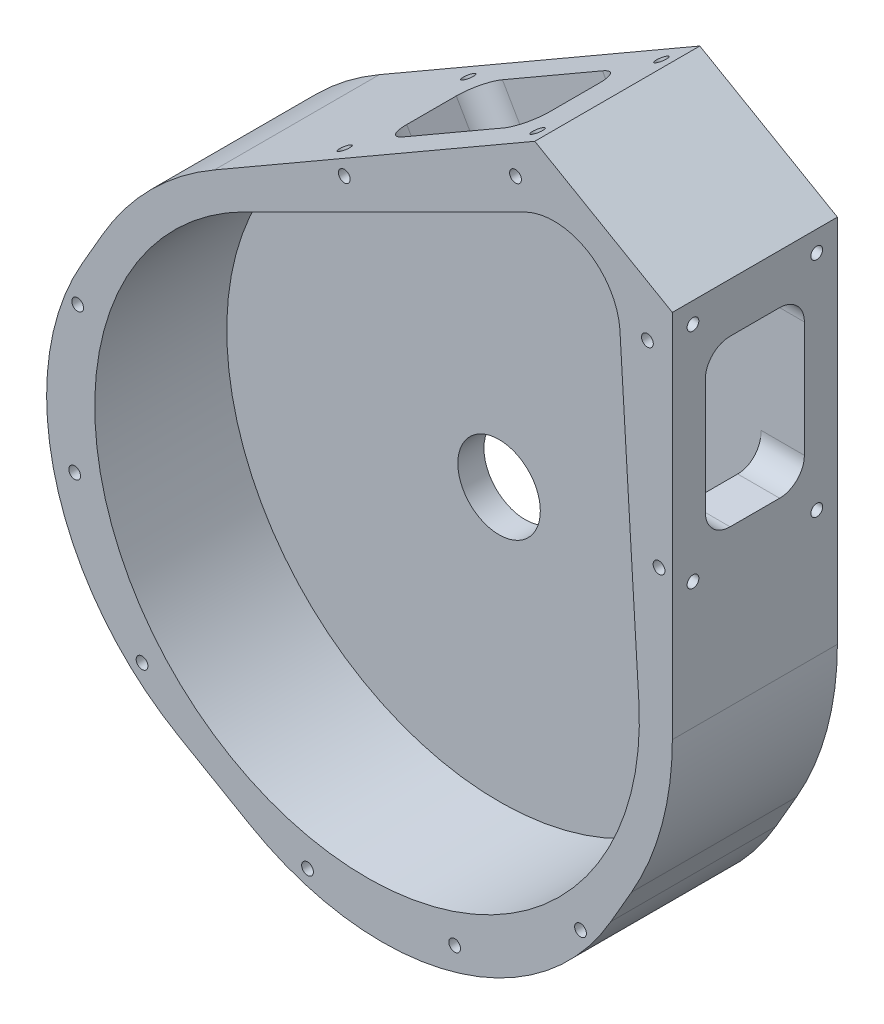
from build123d import *

# Parameters (mm, degrees)
BOSS_EXTRUDE1_DEPTH            = 31.75
CUT_EXTRUDE3_DEPTH             = 25.4
CUT_EXTRUDE4_DEPTH             = 41.472686
F_4_40_TAPPED_HOLE1_AT_2_COUNT = 2
F_4_40_TAPPED_HOLE1_AT_2_PITCH = 23.8125
F_4_40_TAPPED_HOLE1_AT_3_COUNT = 2
F_4_40_TAPPED_HOLE1_AT_3_PITCH = 49.032938546
F_4_40_TAPPED_HOLE1_AT_4_COUNT = 2
F_4_40_TAPPED_HOLE1_AT_4_PITCH = 42.8625
F_4_40_TAPPED_HOLE3_AT_2_COUNT = 2
F_4_40_TAPPED_HOLE3_AT_2_PITCH = 105.48665894
F_4_40_TAPPED_HOLE3_AT_3_COUNT = 2
F_4_40_TAPPED_HOLE3_AT_3_PITCH = 124.969097047
F_4_40_TAPPED_HOLE3_AT_4_COUNT = 2
F_4_40_TAPPED_HOLE3_AT_4_PITCH = 36.810720416
F_4_40_TAPPED_HOLE3_AT_5_COUNT = 2
F_4_40_TAPPED_HOLE3_AT_5_PITCH = 137.285419975
SKETCH23_R                     = 7.9375
CUT_EXTRUDE6_DEPTH             = 32.75
SKETCH24_R                     = 10.0076
CUT_EXTRUDE9_DEPTH             = 1.3208
F_2_56_TAPPED_HOLE1_AT_2_COUNT = 2
F_2_56_TAPPED_HOLE1_AT_2_PITCH = 23.23749988
F_2_56_TAPPED_HOLE1_AT_3_COUNT = 2
F_2_56_TAPPED_HOLE1_AT_3_PITCH = 32.862787571
F_2_56_TAPPED_HOLE1_AT_4_COUNT = 2
F_2_56_TAPPED_HOLE1_AT_4_PITCH = 23.2375
LPATTERN1_COUNT                = 2
LPATTERN1_PITCH                = 71.501
F_4_40_TAPPED_HOLE5_AT_2_COUNT = 2
F_4_40_TAPPED_HOLE5_AT_2_PITCH = 12.7
F_4_40_TAPPED_HOLE5_AT_3_COUNT = 2
F_4_40_TAPPED_HOLE5_AT_3_PITCH = 95.193833559
FILLET3_R                      = 50.8


with BuildPart() as part:
    # Sketch1 (on Front Plane) → Boss-Extrude1 (new body)
    with BuildSketch(Plane.XY):
        with BuildLine():
            Line((58.7375, 0), (58.7375, 71.178534783))
            Line((58.7375, 71.178534783), (32.273669326, 86.457434546))
            Line((32.273669326, 86.457434546), (-29.36875, 50.868167155))
            ThreePointArc((-29.36875, 50.868167155), (-41.53368456, 41.53368456), (-50.868167155, 29.36875))
            Line((-50.868167155, 29.36875), (-80.236917155, -21.499417155))
            Line((-80.236917155, -21.499417155), (21.499417155, -80.236917155))
            Line((21.499417155, -80.236917155), (50.868167155, -29.36875))
            ThreePointArc((50.868167155, -29.36875), (56.736068222, -15.202383662), (58.7375, 0))
        make_face()
    extrude(amount=BOSS_EXTRUDE1_DEPTH)

    # Sketch4 → Cut-Extrude3 (cut)
    with BuildSketch(Plane.XY.offset(31.75)):
        with BuildLine():
            Line((30.568366553, 73.812917761), (-23.525977534, 46.807889691))
            ThreePointArc((-23.525977534, 46.807889691), (-26.19375, -45.368905841), (52.299810337, 3.029850652))
            Line((52.299810337, 3.029850652), (48.639678632, 63.379440867))
            ThreePointArc((48.639678632, 63.379440867), (42.332250779, 73.321609148), (30.568366553, 73.812917761))
        make_face()
    extrude(amount=-CUT_EXTRUDE3_DEPTH, mode=Mode.SUBTRACT)

    # Sketch5 → Cut-Extrude4 (cut)
    with BuildSketch(Plane(origin=(58.7375, 0, 0), x_dir=(0, 0, -1), z_dir=(1, 0, 0))):
        with BuildLine():
            Line((-20.6375, 29.903534783), (-11.1125, 29.903534783))
            ThreePointArc((-11.1125, 29.903534783), (-7.744903955, 31.298438737), (-6.35, 34.666034783))
            Line((-6.35, 34.666034783), (-6.35, 56.891034783))
            ThreePointArc((-6.35, 56.891034783), (-7.744903955, 60.258630828), (-11.1125, 61.653534783))
            Line((-11.1125, 61.653534783), (-20.6375, 61.653534783))
            ThreePointArc((-20.6375, 61.653534783), (-24.005096045, 60.258630828), (-25.4, 56.891034783))
            Line((-25.4, 56.891034783), (-25.4, 34.666034783))
            ThreePointArc((-25.4, 34.666034783), (-24.005096045, 31.298438737), (-20.6375, 29.903534783))
        make_face()
    cut_extrude4 = extrude(amount=-CUT_EXTRUDE4_DEPTH, mode=Mode.SUBTRACT)

    # Sketch11 → #4-40 Tapped Hole1 (revolve, cut)
    with BuildSketch(Plane(origin=(58.7375, 24.347284783, 27.78125), x_dir=(0, 0, -1), z_dir=(0, 1, 0))):
        Polygon((0, 0), (0, 5.759152758), (1.1303, 5.08), (1.1303, 0), align=None)
    f_4_40_tapped_hole1 = revolve(axis=Axis((65.0875, 24.347284783, 27.78125), (-1, 0, 0)), mode=Mode.SUBTRACT)

    # #4-40 Tapped Hole1 at 2: #4-40 Tapped Hole1 ×2
    with Locations(*[(0, 0, -i * F_4_40_TAPPED_HOLE1_AT_2_PITCH) for i in range(1, F_4_40_TAPPED_HOLE1_AT_2_COUNT)]):
        add(f_4_40_tapped_hole1, mode=Mode.SUBTRACT)

    # #4-40 Tapped Hole1 at 3: #4-40 Tapped Hole1 ×2
    with Locations(*[Vector(0, 0.874157276, -0.485642931) * (i * F_4_40_TAPPED_HOLE1_AT_3_PITCH) for i in range(1, F_4_40_TAPPED_HOLE1_AT_3_COUNT)]):
        add(f_4_40_tapped_hole1, mode=Mode.SUBTRACT)

    # #4-40 Tapped Hole1 at 4: #4-40 Tapped Hole1 ×2
    with Locations(*[(0, i * F_4_40_TAPPED_HOLE1_AT_4_PITCH, 0) for i in range(1, F_4_40_TAPPED_HOLE1_AT_4_COUNT)]):
        add(f_4_40_tapped_hole1, mode=Mode.SUBTRACT)

    # Mirror1: #4-40 Tapped Hole1, Cut-Extrude4 across plane
    add(f_4_40_tapped_hole1.mirror(Plane(origin=(45.505584663, 78.817984664, 31.75), x_dir=(0, 0, 1), z_dir=(-0.866025404, 0.5, 0))), mode=Mode.SUBTRACT)
    add(cut_extrude4.mirror(Plane(origin=(45.505584663, 78.817984664, 31.75), x_dir=(0, 0, 1), z_dir=(-0.866025404, 0.5, 0))), mode=Mode.SUBTRACT)

    # Mirror1 copy 1 sketch → Mirror1 copy 1 (revolve, cut)
    with BuildSketch(Plane(origin=(-8.283382865, 63.041809546, 3.96875), x_dir=(0, 0, -1), z_dir=(0.866025404, 0.5, 0))):
        Polygon((0, 0), (0, -5.759152758), (1.1303, -5.08), (1.1303, 0), align=None)
    revolve(axis=Axis((-11.458382865, 68.54107086, 3.96875), (-0.5, 0.866025404, 0)), mode=Mode.SUBTRACT)

    # Mirror1 copy 2 sketch → Mirror1 copy 2 (revolve, cut)
    with BuildSketch(Plane(origin=(28.836631005, 84.473059546, 3.96875), x_dir=(0, 0, -1), z_dir=(0.866025404, 0.5, 0))):
        Polygon((0, 0), (0, -5.759152758), (1.1303, -5.08), (1.1303, 0), align=None)
    revolve(axis=Axis((25.661631005, 89.97232086, 3.96875), (-0.5, 0.866025404, 0)), mode=Mode.SUBTRACT)

    # Mirror1 copy 3 sketch → Mirror1 copy 3 (revolve, cut)
    with BuildSketch(Plane(origin=(28.836631005, 84.473059546, 27.78125), x_dir=(0, 0, -1), z_dir=(0.866025404, 0.5, 0))):
        Polygon((0, 0), (0, -5.759152758), (1.1303, -5.08), (1.1303, 0), align=None)
    revolve(axis=Axis((25.661631005, 89.97232086, 27.78125), (-0.5, 0.866025404, 0)), mode=Mode.SUBTRACT)

    # Sketch21 → #4-40 Tapped Hole3 (revolve, cut)
    with BuildSketch(Plane(origin=(28.563997799, 78.776138947, 31.75), x_dir=(0, -1, 0), z_dir=(1, 0, 0))):
        Polygon((0, 0), (0, 9.569152758), (1.1303, 8.89), (1.1303, 0), align=None)
    f_4_40_tapped_hole3 = revolve(axis=Axis((28.563997799, 78.776138947, 38.1), (0, 0, -1)), mode=Mode.SUBTRACT)

    # #4-40 Tapped Hole3 at 2: #4-40 Tapped Hole3 ×2
    with Locations(*[Vector(-0.798570247, -0.60190162, 0) * (i * F_4_40_TAPPED_HOLE3_AT_2_PITCH) for i in range(1, F_4_40_TAPPED_HOLE3_AT_2_COUNT)]):
        add(f_4_40_tapped_hole3, mode=Mode.SUBTRACT)

    # #4-40 Tapped Hole3 at 3: #4-40 Tapped Hole3 ×2
    with Locations(*[Vector(-0.678682797, -0.734431522, 0) * (i * F_4_40_TAPPED_HOLE3_AT_3_PITCH) for i in range(1, F_4_40_TAPPED_HOLE3_AT_3_COUNT)]):
        add(f_4_40_tapped_hole3, mode=Mode.SUBTRACT)

    # #4-40 Tapped Hole3 at 4: #4-40 Tapped Hole3 ×2
    with Locations(*[Vector(-0.894837014, -0.44639301, 0) * (i * F_4_40_TAPPED_HOLE3_AT_4_PITCH) for i in range(1, F_4_40_TAPPED_HOLE3_AT_4_COUNT)]):
        add(f_4_40_tapped_hole3, mode=Mode.SUBTRACT)

    # #4-40 Tapped Hole3 at 5: #4-40 Tapped Hole3 ×2
    with Locations(*[Vector(-0.523334145, -0.852127557, 0) * (i * F_4_40_TAPPED_HOLE3_AT_5_PITCH) for i in range(1, F_4_40_TAPPED_HOLE3_AT_5_COUNT)]):
        add(f_4_40_tapped_hole3, mode=Mode.SUBTRACT)

    # Mirror2: #4-40 Tapped Hole3 across plane
    add(f_4_40_tapped_hole3.mirror(Plane(origin=(45.505584663, 78.817984664, 31.75), x_dir=(0, 0, 1), z_dir=(-0.866025404, 0.5, 0))), mode=Mode.SUBTRACT)

    # Mirror2 copy 1 sketch → Mirror2 copy 1 (revolve, cut)
    with BuildSketch(Plane(origin=(41.073195613, -40.573765561, 31.75), x_dir=(-0.866025404, -0.5, 0), z_dir=(-0.5, 0.866025404, 0))):
        Polygon((0, 0), (0, -9.569152758), (1.1303, -8.89), (1.1303, 0), align=None)
    revolve(axis=Axis((41.073195613, -40.573765561, 38.1), (0, 0, 1)), mode=Mode.SUBTRACT)

    # Mirror2 copy 2 sketch → Mirror2 copy 2 (revolve, cut)
    with BuildSketch(Plane(origin=(16.862437785, -55.216809411, 31.75), x_dir=(-0.866025404, -0.5, 0), z_dir=(-0.5, 0.866025404, 0))):
        Polygon((0, 0), (0, -9.569152758), (1.1303, -8.89), (1.1303, 0), align=None)
    revolve(axis=Axis((16.862437785, -55.216809411, 38.1), (0, 0, 1)), mode=Mode.SUBTRACT)

    # Mirror2 copy 3 sketch → Mirror2 copy 3 (revolve, cut)
    with BuildSketch(Plane(origin=(56.179364962, 27.382666896, 31.75), x_dir=(-0.866025404, -0.5, 0), z_dir=(-0.5, 0.866025404, 0))):
        Polygon((0, 0), (0, -9.569152758), (1.1303, -8.89), (1.1303, 0), align=None)
    revolve(axis=Axis((56.179364962, 27.382666896, 38.1), (0, 0, 1)), mode=Mode.SUBTRACT)

    # Mirror2 copy 4 sketch → Mirror2 copy 4 (revolve, cut)
    with BuildSketch(Plane(origin=(-11.448500353, -56.58771677, 31.75), x_dir=(-0.866025404, -0.5, 0), z_dir=(-0.5, 0.866025404, 0))):
        Polygon((0, 0), (0, -9.569152758), (1.1303, -8.89), (1.1303, 0), align=None)
    revolve(axis=Axis((-11.448500353, -56.58771677, 38.1), (0, 0, 1)), mode=Mode.SUBTRACT)

    # Sketch23 → Cut-Extrude6 (cut, through all)
    with BuildSketch(Plane(origin=(0, 0, 0), x_dir=(-1, 0, 0), z_dir=(0, 0, -1))):
        Circle(SKETCH23_R)
        with Locations((-35.818522025, 62.0395)):
            Circle(SKETCH23_R)
    extrude(amount=-CUT_EXTRUDE6_DEPTH, mode=Mode.SUBTRACT)

    # Sketch24 → Cut-Extrude9 (cut)
    with BuildSketch(Plane(origin=(0, 0, 0), x_dir=(-1, 0, 0), z_dir=(0, 0, -1))):
        Circle(SKETCH24_R)
        with Locations((-35.818522025, 62.0395)):
            Circle(SKETCH24_R)
    extrude(amount=-CUT_EXTRUDE9_DEPTH, mode=Mode.SUBTRACT)

    # Sketch26 → #4-40 Tapped Hole4 (revolve, cut)
    with BuildSketch(Plane(origin=(35.818522025, 46.0375, 6.35), x_dir=(0, -1, 0), z_dir=(1, 0, 0))):
        Polygon((0, 0), (0, 4.997152758), (1.1303, 4.318), (1.1303, 0), align=None)
    f_4_40_tapped_hole4 = revolve(axis=Axis((35.818522025, 46.0375, 12.7), (0, 0, -1)), mode=Mode.SUBTRACT)

    # Mirror3: #4-40 Tapped Hole4 across plane
    add(f_4_40_tapped_hole4.mirror(Plane(origin=(45.505584663, 78.817984664, 31.75), x_dir=(0, 0, 1), z_dir=(-0.866025404, 0.5, 0))), mode=Mode.SUBTRACT)

    # Sketch28 → #2-56 Tapped Hole1 (revolve, cut)
    with BuildSketch(Plane(origin=(51.690029634, 66.29225769, 0), x_dir=(0, 1, 0), z_dir=(1, 0, 0))):
        Polygon((0, 0), (0, 4.34416509), (0.889, 3.81), (0.889, 0), align=None)
    f_2_56_tapped_hole1 = revolve(axis=Axis((51.690029634, 66.29225769, -6.35), (0, 0, 1)), mode=Mode.SUBTRACT)

    # #2-56 Tapped Hole1 at 2: #2-56 Tapped Hole1 ×2
    with Locations(*[Vector(-0.866025404, 0.5, 0) * (i * F_2_56_TAPPED_HOLE1_AT_2_PITCH) for i in range(1, F_2_56_TAPPED_HOLE1_AT_2_COUNT)]):
        add(f_2_56_tapped_hole1, mode=Mode.SUBTRACT)

    # #2-56 Tapped Hole1 at 3: #2-56 Tapped Hole1 ×2
    with Locations(*[Vector(-0.965925826, -0.258819048, 0) * (i * F_2_56_TAPPED_HOLE1_AT_3_PITCH) for i in range(1, F_2_56_TAPPED_HOLE1_AT_3_COUNT)]):
        add(f_2_56_tapped_hole1, mode=Mode.SUBTRACT)

    # #2-56 Tapped Hole1 at 4: #2-56 Tapped Hole1 ×2
    with Locations(*[Vector(-0.5, -0.866025404, 0) * (i * F_2_56_TAPPED_HOLE1_AT_4_PITCH) for i in range(1, F_2_56_TAPPED_HOLE1_AT_4_COUNT)]):
        add(f_2_56_tapped_hole1, mode=Mode.SUBTRACT)

    # LPattern1: #2-56 Tapped Hole1 ×2
    with Locations(*[Vector(-0.5, -0.866025404, 0) * (i * LPATTERN1_PITCH) for i in range(1, LPATTERN1_COUNT)]):
        add(f_2_56_tapped_hole1, mode=Mode.SUBTRACT)

    # LPattern1 copy 1 sketch → LPattern1 copy 1 (revolve, cut)
    with BuildSketch(Plane(origin=(-4.184735583, 15.989325234, 0), x_dir=(0, 1, 0), z_dir=(1, 0, 0))):
        Polygon((0, 0), (0, 4.34416509), (0.889, 3.81), (0.889, 0), align=None)
    revolve(axis=Axis((-4.184735583, 15.989325234, -6.35), (0, 0, 1)), mode=Mode.SUBTRACT)

    # LPattern1 copy 2 sketch → LPattern1 copy 2 (revolve, cut)
    with BuildSketch(Plane(origin=(-15.803485583, -4.134940086, 0), x_dir=(0, 1, 0), z_dir=(1, 0, 0))):
        Polygon((0, 0), (0, 4.34416509), (0.889, 3.81), (0.889, 0), align=None)
    revolve(axis=Axis((-15.803485583, -4.134940086, -6.35), (0, 0, 1)), mode=Mode.SUBTRACT)

    # LPattern1 copy 3 sketch → LPattern1 copy 3 (revolve, cut)
    with BuildSketch(Plane(origin=(4.320779634, -15.753690026, 0), x_dir=(0, 1, 0), z_dir=(1, 0, 0))):
        Polygon((0, 0), (0, 4.34416509), (0.889, 3.81), (0.889, 0), align=None)
    revolve(axis=Axis((4.320779634, -15.753690026, -6.35), (0, 0, 1)), mode=Mode.SUBTRACT)

    # Sketch31 → #4-40 Tapped Hole5 (revolve, cut)
    with BuildSketch(Plane(origin=(-44.943536498, 33.280511314, 0), x_dir=(0, 1, 0), z_dir=(1, 0, 0))):
        Polygon((0, 0), (0, 9.569152758), (1.1303, 8.89), (1.1303, 0), align=None)
    f_4_40_tapped_hole5 = revolve(axis=Axis((-44.943536498, 33.280511314, -6.35), (0, 0, 1)), mode=Mode.SUBTRACT)

    # #4-40 Tapped Hole5 at 2: #4-40 Tapped Hole5 ×2
    with Locations(*[Vector(-0.5, -0.866025404, 0) * (i * F_4_40_TAPPED_HOLE5_AT_2_PITCH) for i in range(1, F_4_40_TAPPED_HOLE5_AT_2_COUNT)]):
        add(f_4_40_tapped_hole5, mode=Mode.SUBTRACT)

    # #4-40 Tapped Hole5 at 3: #4-40 Tapped Hole5 ×2
    with Locations(*[Vector(0.875711763, 0.482834244, 0) * (i * F_4_40_TAPPED_HOLE5_AT_3_PITCH) for i in range(1, F_4_40_TAPPED_HOLE5_AT_3_COUNT)]):
        add(f_4_40_tapped_hole5, mode=Mode.SUBTRACT)

    # Mirror4: #4-40 Tapped Hole5 across plane
    add(f_4_40_tapped_hole5.mirror(Plane(origin=(45.505584663, 78.817984664, 31.75), x_dir=(0, 0, 1), z_dir=(-0.866025404, 0.5, 0))), mode=Mode.SUBTRACT)

    # Mirror4 copy 1 sketch → Mirror4 copy 1 (revolve, cut)
    with BuildSketch(Plane(origin=(44.943536498, -33.280511314, 0), x_dir=(0.866025404, 0.5, 0), z_dir=(-0.5, 0.866025404, 0))):
        Polygon((0, 0), (0, -9.569152758), (1.1303, -8.89), (1.1303, 0), align=None)
    revolve(axis=Axis((44.943536498, -33.280511314, -6.35), (0, 0, -1)), mode=Mode.SUBTRACT)

    # Mirror4 copy 2 sketch → Mirror4 copy 2 (revolve, cut)
    with BuildSketch(Plane(origin=(49.417345977, 72.893354007, 0), x_dir=(0.866025404, 0.5, 0), z_dir=(-0.5, 0.866025404, 0))):
        Polygon((0, 0), (0, -9.569152758), (1.1303, -8.89), (1.1303, 0), align=None)
    revolve(axis=Axis((49.417345977, 72.893354007, -6.35), (0, 0, -1)), mode=Mode.SUBTRACT)

    # Fillet3
    fillet3_edges = [part.edges().sort_by_distance(p)[0] for p in [
        (21.499417155, -80.236917155, 15.875),
        (-80.236917155, -21.499417155, 15.875),
    ]]
    fillet(fillet3_edges, radius=FILLET3_R)


solid = part.part
